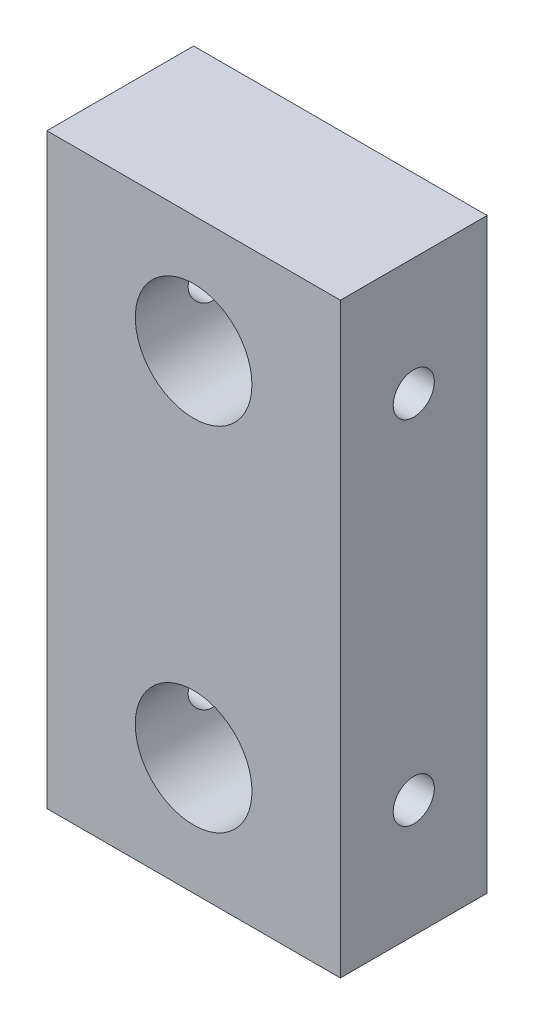
from build123d import *

# Parameters (mm, degrees)
ESQUISSE1_W             = 20
ESQUISSE1_H             = 40
ESQUISSE1_R             = 3.974062066
BOSS_EXTRU_1_DEPTH      = 10
ESQUISSE2_R             = 1.4
ENL_V_MAT_EXTRU_1_DEPTH = 28


with BuildPart() as part:
    # Esquisse1 → Boss.-Extru.1 (new body)
    with BuildSketch(Plane.XY):
        Rectangle(ESQUISSE1_W, ESQUISSE1_H)
        with Locations((0, 12)):
            Circle(ESQUISSE1_R, mode=Mode.SUBTRACT)
        with Locations((0, -12)):
            Circle(ESQUISSE1_R, mode=Mode.SUBTRACT)
    extrude(amount=BOSS_EXTRU_1_DEPTH)

    # Esquisse2 → Enlèv. mat.-Extru.1 (cut)
    with BuildSketch(Plane.ZY.offset(10)):
        with Locations((5, 12)):
            Circle(ESQUISSE2_R)
        with Locations((5, -12)):
            Circle(ESQUISSE2_R)
    extrude(amount=-ENL_V_MAT_EXTRU_1_DEPTH, mode=Mode.SUBTRACT)


solid = part.part
